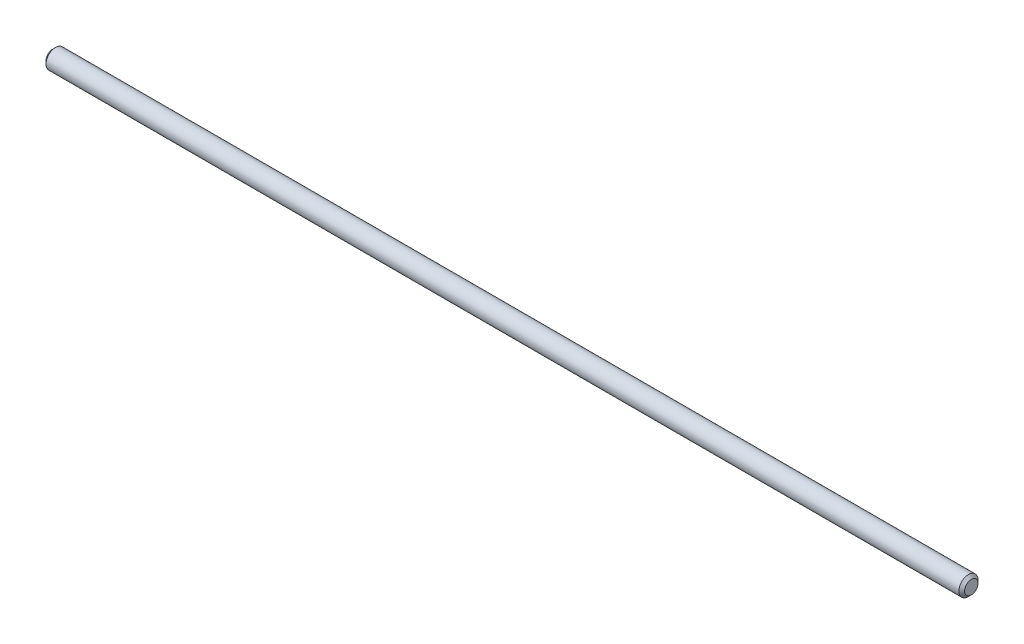
from build123d import *

# Parameters (mm, degrees)
SKETCH2_R                = 3.175
BOSS_EXTRUDE1_DEPTH      = 152.4
BOSS_EXTRUDE1_DEPTH_BACK = 152.4
CHAMFER1_SIZE            = 0.9525


with BuildPart() as part:
    # Sketch2 → Boss-Extrude1 (new body, two sides)
    with BuildSketch(Plane(origin=(0, 0, 0), x_dir=(0, 0, -1), z_dir=(1, 0, 0))) as boss_extrude1_sk:
        Circle(SKETCH2_R)
    extrude(amount=BOSS_EXTRUDE1_DEPTH)
    extrude(boss_extrude1_sk.sketch, amount=-BOSS_EXTRUDE1_DEPTH_BACK)

    # Chamfer1
    chamfer1_edges = [part.edges().sort_by_distance(p)[0] for p in [
        (-152.4, 0, 3.175),
        (152.4, 0, 3.175),
    ]]
    chamfer(chamfer1_edges, length=CHAMFER1_SIZE)


solid = part.part
